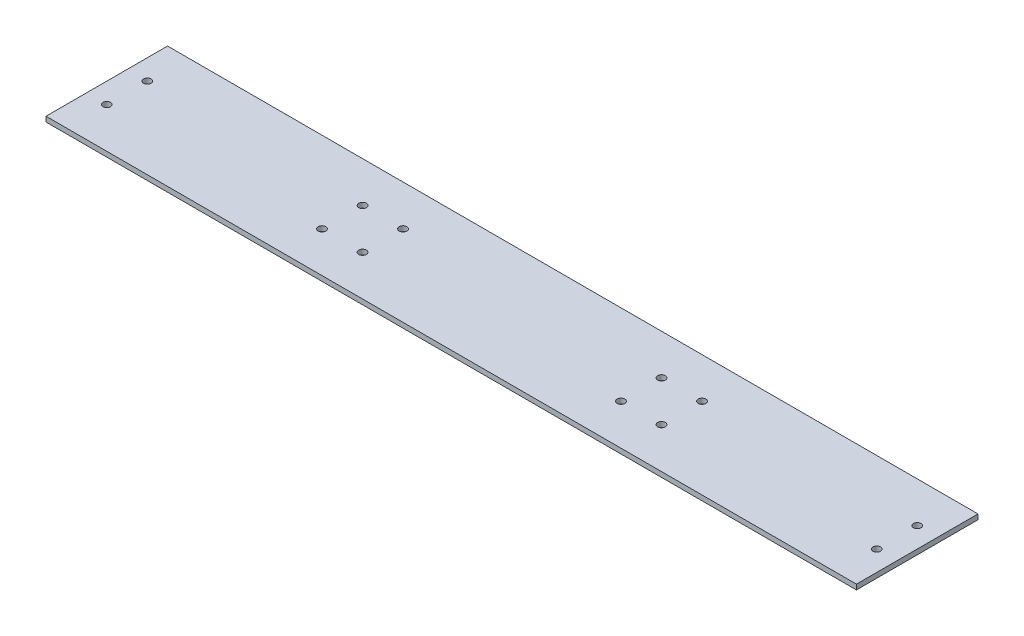
from build123d import *

# Parameters (mm, degrees)
SKETCH1_W           = 508
SKETCH1_H           = 76.2
BOSS_EXTRUDE1_DEPTH = 3.175
SKETCH2_R           = 2.413
CUT_EXTRUDE1_DEPTH  = 3.175
SKETCH3_R           = 2.38125
CUT_EXTRUDE2_DEPTH  = 3.175


with BuildPart() as part:
    # Sketch1 → Boss-Extrude1 (new body)
    with BuildSketch(Plane(origin=(0, 0, 0), x_dir=(1, 0, 0), z_dir=(0, 1, 0))):
        Rectangle(SKETCH1_W, SKETCH1_H)
    extrude(amount=BOSS_EXTRUDE1_DEPTH)

    # Sketch2 → Cut-Extrude1 (cut)
    with BuildSketch(Plane(origin=(0, 3.175, 0), x_dir=(1, 0, 0), z_dir=(0, 1, 0))):
        with Locations((-106.339909649, -12.738500789)):
            Circle(SKETCH2_R)
        with Locations((-106.339909649, 12.661499211)):
            Circle(SKETCH2_R)
        with Locations((-80.939909649, 12.661499211)):
            Circle(SKETCH2_R)
        with Locations((-80.939909649, -12.738500789)):
            Circle(SKETCH2_R)
        with Locations((106.338702735, -12.620374528)):
            Circle(SKETCH2_R)
        with Locations((106.338702735, 12.779625472)):
            Circle(SKETCH2_R)
        with Locations((80.938702735, 12.779625472)):
            Circle(SKETCH2_R)
        with Locations((80.938702735, -12.620374528)):
            Circle(SKETCH2_R)
    extrude(amount=-CUT_EXTRUDE1_DEPTH, mode=Mode.SUBTRACT)

    # Sketch3 → Cut-Extrude2 (cut)
    with BuildSketch(Plane(origin=(0, 3.175, 0), x_dir=(1, 0, 0), z_dir=(0, 1, 0))):
        with Locations((-241.3, 12.7)):
            Circle(SKETCH3_R)
        with Locations((-241.3, -12.7)):
            Circle(SKETCH3_R)
        with Locations((241.3, -12.7)):
            Circle(SKETCH3_R)
        with Locations((241.3, 12.7)):
            Circle(SKETCH3_R)
    extrude(amount=-CUT_EXTRUDE2_DEPTH, mode=Mode.SUBTRACT)


solid = part.part
